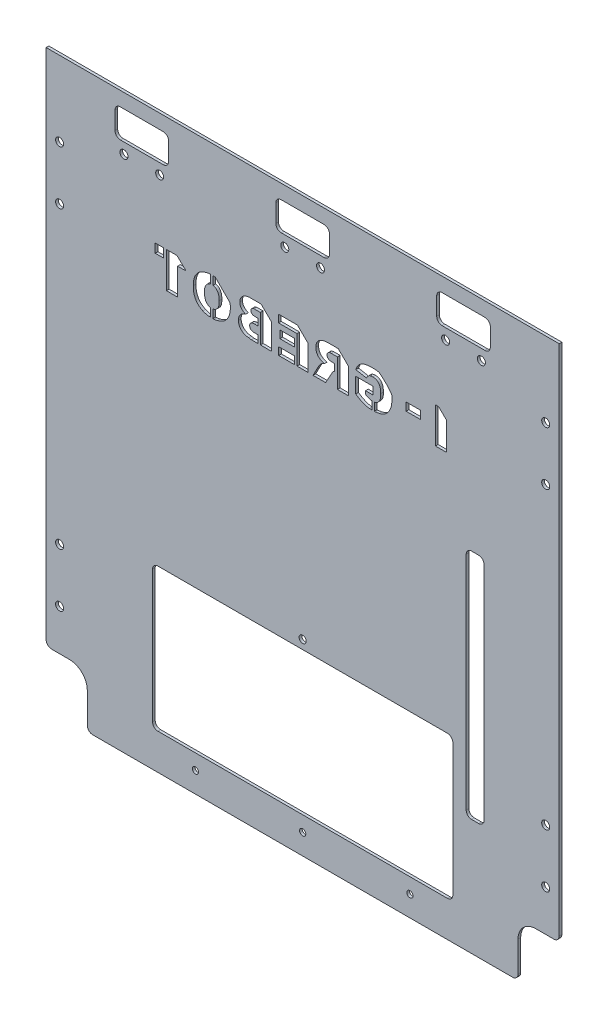
from build123d import *

# Parameters (mm, degrees)
ESQUISSE1_W                  = 287
ESQUISSE1_H                  = 320
BOSS_EXTRU_1_DEPTH           = 1.5
ESQUISSE2_W                  = 23
ESQUISSE2_H                  = 30
ENL_V_MAT_EXTRU_1_DEPTH      = 1
ENL_V_MAT_EXTRU_1_DEPTH_BACK = 2.5
CONG_1_R                     = 10
CONG_2_R                     = 3
ESQUISSE3_W                  = 10
ESQUISSE3_H                  = 130
ENL_V_MAT_EXTRU_2_DEPTH      = 1
ENL_V_MAT_EXTRU_2_DEPTH_BACK = 2.5
ESQUISSE4_W                  = 168
ESQUISSE4_H                  = 80
ENL_V_MAT_EXTRU_3_DEPTH      = 1
ENL_V_MAT_EXTRU_3_DEPTH_BACK = 2.5
CONG_3_R                     = 3
ESQUISSE5_R                  = 2
ESQUISSE5_R_2                = 1.75
ENL_V_MAT_EXTRU_4_DEPTH      = 1
ENL_V_MAT_EXTRU_4_DEPTH_BACK = 2.5
ESQUISSE6_R                  = 2.25
ENL_V_MAT_EXTRU_5_DEPTH      = 1
ENL_V_MAT_EXTRU_5_DEPTH_BACK = 2.5
ESQUISSE7_W                  = 30
ESQUISSE7_H                  = 16
ENL_V_MAT_EXTRU_6_DEPTH      = 1
ENL_V_MAT_EXTRU_6_DEPTH_BACK = 2.5
CONG_4_R                     = 3
ESQUISSE8_W                  = 8
ESQUISSE8_H                  = 4.5
ESQUISSE8_W_2                = 8.1015625
ESQUISSE8_H_2                = 4.25
ESQUISSE8_W_3                = 8.83203125
ESQUISSE8_W_4                = 4.75
ESQUISSE8_H_3                = 5
ENL_V_MAT_EXTRU_9_DEPTH      = 2.5
ENL_V_MAT_EXTRU_9_DEPTH_BACK = 1


with BuildPart() as part:
    # Esquisse1 → Boss.-Extru.1 (new body)
    with BuildSketch(Plane.XY):
        with Locations((143.5, 160)):
            Rectangle(ESQUISSE1_W, ESQUISSE1_H)
    extrude(amount=BOSS_EXTRU_1_DEPTH)

    # Esquisse2 → Enlèv. mat.-Extru.1 (cut, two sides)
    with BuildSketch(Plane.XY.offset(1.5)) as enl_v_mat_extru_1_sk:
        with Locations((275.5, 15)):
            Rectangle(ESQUISSE2_W, ESQUISSE2_H)
        with Locations((11.5, 15)):
            Rectangle(ESQUISSE2_W, ESQUISSE2_H)
    extrude(amount=ENL_V_MAT_EXTRU_1_DEPTH, mode=Mode.SUBTRACT)
    extrude(enl_v_mat_extru_1_sk.sketch, amount=-ENL_V_MAT_EXTRU_1_DEPTH_BACK, mode=Mode.SUBTRACT)

    # Congé1
    cong_1_edges = [part.edges().sort_by_distance(p)[0] for p in [
        (264, 30, 0.75),
        (23, 30, 0.75),
    ]]
    fillet(cong_1_edges, radius=CONG_1_R)

    # Congé2
    cong_2_edges = [part.edges().sort_by_distance(p)[0] for p in [
        (287, 30, 0.75),
        (264, 0, 0.75),
        (23, 0, 0.75),
        (0, 30, 0.75),
    ]]
    fillet(cong_2_edges, radius=CONG_2_R)

    # Esquisse3 → Enlèv. mat.-Extru.2 (cut, two sides)
    with BuildSketch(Plane.XY.offset(1.5)) as enl_v_mat_extru_2_sk:
        with Locations((240, 130)):
            Rectangle(ESQUISSE3_W, ESQUISSE3_H)
    extrude(amount=ENL_V_MAT_EXTRU_2_DEPTH, mode=Mode.SUBTRACT)
    extrude(enl_v_mat_extru_2_sk.sketch, amount=-ENL_V_MAT_EXTRU_2_DEPTH_BACK, mode=Mode.SUBTRACT)

    # Esquisse4 → Enlèv. mat.-Extru.3 (cut, two sides)
    with BuildSketch(Plane.XY.offset(1.5)) as enl_v_mat_extru_3_sk:
        with Locations((143.5, 60)):
            Rectangle(ESQUISSE4_W, ESQUISSE4_H)
    extrude(amount=ENL_V_MAT_EXTRU_3_DEPTH, mode=Mode.SUBTRACT)
    extrude(enl_v_mat_extru_3_sk.sketch, amount=-ENL_V_MAT_EXTRU_3_DEPTH_BACK, mode=Mode.SUBTRACT)

    # Congé3
    cong_3_edges = [part.edges().sort_by_distance(p)[0] for p in [
        (59.5, 20, 0.75),
        (59.5, 100, 0.75),
        (227.5, 100, 0.75),
        (227.5, 20, 0.75),
        (235, 65, 0.75),
        (235, 195, 0.75),
        (245, 195, 0.75),
        (245, 65, 0.75),
    ]]
    fillet(cong_3_edges, radius=CONG_3_R)

    # Esquisse5 → Enlèv. mat.-Extru.4 (cut, two sides)
    with BuildSketch(Plane.XY.offset(1.5)) as enl_v_mat_extru_4_sk:
        with Locations((143.5, 105)):
            Circle(ESQUISSE5_R)
        with Locations((83.5, 11.5)):
            Circle(ESQUISSE5_R_2)
        with Locations((143.5, 11.5)):
            Circle(ESQUISSE5_R_2)
        with Locations((203.5, 11.5)):
            Circle(ESQUISSE5_R_2)
    extrude(amount=ENL_V_MAT_EXTRU_4_DEPTH, mode=Mode.SUBTRACT)
    extrude(enl_v_mat_extru_4_sk.sketch, amount=-ENL_V_MAT_EXTRU_4_DEPTH_BACK, mode=Mode.SUBTRACT)

    # Esquisse6 → Enlèv. mat.-Extru.5 (cut, two sides)
    with BuildSketch(Plane.XY.offset(1.5)) as enl_v_mat_extru_5_sk:
        with Locations((279.5, 83)):
            Circle(ESQUISSE6_R)
        with Locations((279.5, 53)):
            Circle(ESQUISSE6_R)
        with Locations((279.5, 278)):
            Circle(ESQUISSE6_R)
        with Locations((279.5, 248)):
            Circle(ESQUISSE6_R)
        with Locations((7.5, 248)):
            Circle(ESQUISSE6_R)
        with Locations((7.5, 278)):
            Circle(ESQUISSE6_R)
        with Locations((7.5, 53)):
            Circle(ESQUISSE6_R)
        with Locations((7.5, 83)):
            Circle(ESQUISSE6_R)
        with Locations((133.5, 290)):
            Circle(ESQUISSE6_R)
        with Locations((153.5, 290)):
            Circle(ESQUISSE6_R)
        with Locations((43.5, 290)):
            Circle(ESQUISSE6_R)
        with Locations((63.5, 290)):
            Circle(ESQUISSE6_R)
        with Locations((223.5, 290)):
            Circle(ESQUISSE6_R)
        with Locations((243.5, 290)):
            Circle(ESQUISSE6_R)
    extrude(amount=ENL_V_MAT_EXTRU_5_DEPTH, mode=Mode.SUBTRACT)
    extrude(enl_v_mat_extru_5_sk.sketch, amount=-ENL_V_MAT_EXTRU_5_DEPTH_BACK, mode=Mode.SUBTRACT)

    # Esquisse7 → Enlèv. mat.-Extru.6 (cut, two sides)
    with BuildSketch(Plane.XY.offset(1.5)) as enl_v_mat_extru_6_sk:
        with Locations((143.5, 304)):
            Rectangle(ESQUISSE7_W, ESQUISSE7_H)
        with Locations((53.5, 304)):
            Rectangle(ESQUISSE7_W, ESQUISSE7_H)
        with Locations((233.5, 304)):
            Rectangle(ESQUISSE7_W, ESQUISSE7_H)
    extrude(amount=ENL_V_MAT_EXTRU_6_DEPTH, mode=Mode.SUBTRACT)
    extrude(enl_v_mat_extru_6_sk.sketch, amount=-ENL_V_MAT_EXTRU_6_DEPTH_BACK, mode=Mode.SUBTRACT)

    # Congé4
    cong_4_edges = [part.edges().sort_by_distance(p)[0] for p in [
        (158.5, 296, 0.75),
        (128.5, 296, 0.75),
        (128.5, 312, 0.75),
        (158.5, 312, 0.75),
        (68.5, 296, 0.75),
        (38.5, 296, 0.75),
        (38.5, 312, 0.75),
        (68.5, 312, 0.75),
        (218.5, 312, 0.75),
        (248.5, 312, 0.75),
        (248.5, 296, 0.75),
        (218.5, 296, 0.75),
    ]]
    fillet(cong_4_edges, radius=CONG_4_R)

    # Esquisse8 → Enlèv. mat.-Extru.9 (cut, two sides)
    with BuildSketch(Plane.XY) as enl_v_mat_extru_9_sk:
        with Locations((205.40307235, 246.717470335)):
            Rectangle(ESQUISSE8_W, ESQUISSE8_H)
        Polygon((217.808470064, 235.82100052), (224.058470064, 235.82100052), (224.058470064, 251.35615677), (219.554563814, 255.82100052), (217.808470064, 255.82100052), align=None)
        with BuildLine():
            add(Edge.make_bspline(
                [(173.195970064, 238.68428177), (173.506575511, 238.476890691), (174.124030723, 238.064616198), (175.081740291, 237.500188658), (176.060170837, 236.990331228), (177.048885734, 236.534146379), (178.03415498, 236.149028744), (179.004739272, 235.859814208), (179.950320427, 235.655338937), (180.576615749, 235.598734129), (180.883470064, 235.57100052)],
                knots=[0, 0, 0, 0, 0.001120277, 0.002227008, 0.00333298, 0.004428918, 0.005492394, 0.006503351, 0.007464805, 0.008388375, 0.008388375, 0.008388375, 0.008388375], degree=3))
            add(Edge.make_bspline(
                [(180.883470064, 235.57100052), (180.956386731, 235.57100052), (181.123053398, 235.57100052), (181.373053398, 235.57100052), (181.597011731, 235.57100052), (181.727220064, 235.57100052), (181.774095064, 235.57100052)],
                knots=[0, 0, 0, 0, 0.00021875, 0.0005, 0.00075, 0.000890625, 0.000890625, 0.000890625, 0.000890625], degree=3))
            Line((181.774095064, 235.57100052), (182.340501314, 235.57100052))
            Line((182.340501314, 235.57100052), (182.340501314, 239.92646927))
            add(Edge.make_bspline(
                [(182.340501314, 239.92646927), (182.010963338, 239.979571057), (181.357346222, 240.084894993), (180.562803563, 240.316303619), (179.951024259, 240.551407006), (179.513510291, 240.772898853), (179.090921227, 241.026275912), (178.82838844, 241.224782459), (178.695970064, 241.32490677)],
                knots=[0, 0, 0, 0, 0.001000641, 0.001984706, 0.002475791, 0.002964931, 0.003453977, 0.003951683, 0.003951683, 0.003951683, 0.003951683], degree=3))
            Line((178.695970064, 241.32490677), (178.695970064, 243.07100052))
            Line((178.695970064, 243.07100052), (182.879563814, 243.07100052))
            Line((182.879563814, 243.07100052), (182.879563814, 247.32100052))
            Line((182.879563814, 247.32100052), (173.195970064, 247.32100052))
            Line((173.195970064, 247.32100052), (173.195970064, 238.68428177))
        make_face()
        with BuildLine():
            Line((173.293626314, 250.55146927), (178.856126314, 249.52412552))
            Line((178.856126314, 249.52412552), (179.285813814, 249.52412552))
            add(Edge.make_bspline(
                [(179.285813814, 249.52412552), (179.336154704, 249.644702546), (179.432958032, 249.876566886), (179.600852687, 250.199180903), (179.784282989, 250.481685008), (180.041005404, 250.799724919), (180.391033417, 251.128577135), (180.85376061, 251.423652978), (181.332932183, 251.629013222), (181.817262437, 251.746217036), (182.286681346, 251.808766376), (182.594238869, 251.817014956), (182.742845064, 251.82100052)],
                knots=[0, 0, 0, 0, 0.000391873, 0.000753555, 0.001089424, 0.001400554, 0.001978164, 0.002521034, 0.00303908, 0.003534574, 0.004011344, 0.004457085, 0.004457085, 0.004457085, 0.004457085], degree=3))
            add(Edge.make_bspline(
                [(182.742845064, 251.82100052), (182.97784203, 251.81449031), (183.42631942, 251.802065972), (184.060845308, 251.682019425), (184.626568121, 251.497206124), (185.107906003, 251.214265838), (185.522588467, 250.883128113), (185.886939282, 250.515696668), (186.199956279, 250.112711627), (186.461110572, 249.676981154), (186.676421177, 249.218099311), (186.84611099, 248.740983979), (186.982772985, 248.249473581), (187.066637417, 247.748715818), (187.123600302, 247.258021362), (187.160627911, 246.791357127), (187.192167949, 246.355274416), (187.19473514, 246.073657365), (187.195970064, 245.93818802)],
                knots=[0, 0, 0, 0, 0.000704209, 0.00134394, 0.001930724, 0.00248016, 0.003008472, 0.003519474, 0.004028922, 0.00453538, 0.005040391, 0.005547, 0.006053021, 0.00656872, 0.007068262, 0.007534745, 0.007973098, 0.008379423, 0.008379423, 0.008379423, 0.008379423], degree=3))
            add(Edge.make_bspline(
                [(187.195970064, 245.93818802), (187.190649886, 245.669855046), (187.179374066, 245.101138317), (187.122077147, 244.376581303), (187.046877928, 243.767068206), (186.948561312, 243.308423519), (186.812950063, 242.861917369), (186.653611626, 242.423167763), (186.443609399, 242.004000166), (186.195680439, 241.602657885), (185.892441631, 241.231848565), (185.55663735, 240.874734006), (185.155219611, 240.562533918), (184.686418742, 240.313616316), (184.157748709, 240.114048435), (183.776874163, 240.036904222), (183.578782564, 239.99678177)],
                knots=[0, 0, 0, 0, 0.000805029, 0.001706213, 0.002179112, 0.00264646, 0.003111156, 0.003578406, 0.004044839, 0.004515214, 0.004990446, 0.005479414, 0.005983381, 0.00650775, 0.00706644, 0.007671921, 0.007671921, 0.007671921, 0.007671921], degree=3))
            Line((183.578782564, 239.99678177), (183.578782564, 235.57100052))
            Line((183.578782564, 235.57100052), (184.121751314, 235.57100052))
            add(Edge.make_bspline(
                [(184.121751314, 235.57100052), (184.15691054, 235.573555002), (184.265082659, 235.581414212), (184.47119009, 235.599090965), (184.754529823, 235.636347134), (185.088933476, 235.674429016), (185.448530211, 235.736678992), (185.817239638, 235.793368752), (186.167058912, 235.867220753), (186.391388784, 235.920824217), (186.496751314, 235.94600052)],
                knots=[0, 0, 0, 0, 0.000105758, 0.000325378, 0.000620448, 0.000962998, 0.001334831, 0.001715004, 0.002081963, 0.002406957, 0.002406957, 0.002406957, 0.002406957], degree=3))
            add(Edge.make_bspline(
                [(186.496751314, 235.94600052), (186.662612098, 235.983109076), (186.990146218, 236.056389319), (187.465479422, 236.198428745), (187.920594462, 236.358545175), (188.354682575, 236.538753763), (188.769979652, 236.736175342), (189.160337699, 236.9600823), (189.53062444, 237.20269951), (189.988217318, 237.555451019), (190.516010405, 238.029204294), (191.084007536, 238.641381576), (191.589874559, 239.287733847), (192.017604439, 239.976709849), (192.378190047, 240.693666504), (192.689298293, 241.424741514), (192.940306741, 242.173092589), (193.128761214, 242.931742428), (193.266097281, 243.685525878), (193.367934857, 244.419218067), (193.435106364, 245.12834141), (193.442394003, 245.592994275), (193.445970064, 245.82100052)],
                knots=[0, 0, 0, 0, 0.000509747, 0.001006624, 0.00148722, 0.001956572, 0.002416067, 0.002865693, 0.003305559, 0.003743076, 0.004597867, 0.005429825, 0.006245558, 0.007056291, 0.007858148, 0.008651126, 0.009437991, 0.01022339, 0.010994139, 0.011735504, 0.012445292, 0.013129165, 0.013129165, 0.013129165, 0.013129165], degree=3))
            add(Edge.make_bspline(
                [(193.445970064, 245.82100052), (193.445880337, 245.968136048), (193.445697705, 246.267615441), (193.447104661, 246.719442178), (193.441842592, 247.166092738), (193.438649849, 247.596096251), (193.411360562, 248.000822611), (193.34421549, 248.371673314), (193.256934469, 248.700923393), (193.145237132, 248.880092088), (193.094407564, 248.96162552)],
                knots=[0, 0, 0, 0, 0.000441406, 0.000898437, 0.001355485, 0.001781338, 0.002188789, 0.002569623, 0.002913106, 0.003199943, 0.003199943, 0.003199943, 0.003199943], degree=3))
            add(Edge.make_bspline(
                [(193.094407564, 248.96162552), (192.854550004, 249.2695013), (192.372846999, 249.887804463), (191.604518746, 250.785097454), (190.800079467, 251.665199844), (189.955437648, 252.522011055), (189.083462986, 253.361905028), (188.179154336, 254.171334401), (187.258051787, 254.965118443), (186.623440187, 255.470183531), (186.305345064, 255.72334427)],
                knots=[0, 0, 0, 0, 0.001170709, 0.002351121, 0.003542757, 0.004747099, 0.005959932, 0.007174172, 0.008387628, 0.009607135, 0.009607135, 0.009607135, 0.009607135], degree=3))
            add(Edge.make_bspline(
                [(186.305345064, 255.72334427), (186.26935064, 255.741567875), (186.163787531, 255.795013385), (185.94337712, 255.832502455), (185.652994511, 255.888454989), (185.311881943, 255.935119257), (184.946654699, 255.987769129), (184.576550236, 256.027566019), (184.236876512, 256.061253522), (184.024152594, 256.068017655), (183.930345064, 256.07100052)],
                knots=[0, 0, 0, 0, 0.000120589, 0.000353658, 0.000663214, 0.001010695, 0.001385247, 0.001770464, 0.002127303, 0.002408797, 0.002408797, 0.002408797, 0.002408797], degree=3))
            add(Edge.make_bspline(
                [(183.930345064, 256.07100052), (183.813157564, 256.07100052), (183.543626314, 256.07100052), (183.195970064, 256.07100052), (182.903001314, 256.07100052), (182.716803398, 256.07100052), (182.578782564, 256.07100052), (182.503261731, 256.07100052), (182.473313814, 256.07100052)],
                knots=[0, 0, 0, 0, 0.000351562, 0.000808594, 0.001042969, 0.001230469, 0.001367188, 0.001457031, 0.001457031, 0.001457031, 0.001457031], degree=3))
            add(Edge.make_bspline(
                [(182.473313814, 256.07100052), (182.040842032, 256.065017718), (181.157820725, 256.052802027), (180.047785286, 255.967518086), (179.146568372, 255.860265255), (178.478616259, 255.711359143), (177.826528903, 255.517290349), (177.18845284, 255.270513321), (176.570787704, 254.964101809), (175.980249258, 254.58389935), (175.41635368, 254.137876568), (174.975592845, 253.708663087), (174.639663437, 253.330839652), (174.403244642, 253.013786861), (174.183427132, 252.670070993), (173.96851457, 252.302967714), (173.780471423, 251.9019041), (173.600619166, 251.477621048), (173.434539314, 251.025737953), (173.34137706, 250.71218321), (173.293626314, 250.55146927)],
                knots=[0, 0, 0, 0, 0.001297251, 0.002648729, 0.003338202, 0.004017811, 0.004698765, 0.005377745, 0.006067782, 0.006763446, 0.007480878, 0.008221213, 0.008605954, 0.008996579, 0.009406139, 0.009829603, 0.010271631, 0.010733775, 0.011212016, 0.011714891, 0.011714891, 0.011714891, 0.011714891], degree=3))
        make_face()
        with BuildLine():
            Line((149.314720064, 235.82100052), (156.314720064, 235.82100052))
            add(Edge.make_bspline(
                [(156.314720064, 235.82100052), (156.477302735, 236.117973252), (156.816192267, 236.736987262), (157.34053737, 237.686292633), (157.879675156, 238.672062079), (158.422756379, 239.65232494), (158.942222648, 240.606684397), (159.375594731, 241.360987201), (159.700793347, 241.927082187), (159.930016711, 242.30702732), (160.137886182, 242.653996198), (160.276484767, 242.870774061), (160.342063814, 242.97334427)],
                knots=[0, 0, 0, 0, 0.001015693, 0.002117124, 0.003253466, 0.004386387, 0.00547909, 0.006513037, 0.006996102, 0.007437578, 0.007844222, 0.00820943, 0.00820943, 0.00820943, 0.00820943], degree=3))
            add(Edge.make_bspline(
                [(160.342063814, 242.97334427), (160.394785732, 243.04431627), (160.504390364, 243.191861356), (160.739415701, 243.354598616), (160.993390005, 243.50299423), (161.171043786, 243.595150771), (161.260032564, 243.64131302)],
                knots=[0, 0, 0, 0, 0.000263578, 0.000547957, 0.000847416, 0.001147969, 0.001147969, 0.001147969, 0.001147969], degree=3))
            Line((161.260032564, 243.64131302), (161.260032564, 247.53975052))
            add(Edge.make_bspline(
                [(161.260032564, 247.53975052), (161.187138913, 247.544297181), (161.02974771, 247.554114283), (160.774349589, 247.555507158), (160.483970818, 247.556643115), (160.050308234, 247.546859442), (159.488083785, 247.564960587), (158.92868774, 247.65090102), (158.497401409, 247.765716817), (158.196601914, 247.896359981), (157.915766782, 248.060008265), (157.650390283, 248.250082786), (157.423298699, 248.500241723), (157.266253078, 248.821622532), (157.173667952, 249.20256887), (157.163730349, 249.476684029), (157.158470064, 249.62178177)],
                knots=[0, 0, 0, 0, 0.000219064, 0.000473, 0.000765969, 0.001090211, 0.001774351, 0.002450595, 0.002783269, 0.00311051, 0.003430774, 0.003757338, 0.0040866, 0.004432496, 0.004819038, 0.005253756, 0.005253756, 0.005253756, 0.005253756], degree=3))
            add(Edge.make_bspline(
                [(157.158470064, 249.62178177), (157.162042215, 249.70782997), (157.168953839, 249.874321537), (157.205680312, 250.114318576), (157.277223561, 250.332662668), (157.408605635, 250.590425684), (157.614586318, 250.875554092), (157.932638637, 251.140890916), (158.295188407, 251.338505367), (158.690591618, 251.468923397), (159.096293462, 251.554095299), (159.36901297, 251.565452977), (159.502220064, 251.57100052)],
                knots=[0, 0, 0, 0, 0.000258286, 0.000499747, 0.000725804, 0.00094417, 0.001366063, 0.001770695, 0.002176287, 0.002597529, 0.003015808, 0.003415182, 0.003415182, 0.003415182, 0.003415182], degree=3))
            Line((159.502220064, 251.57100052), (162.908470064, 251.57100052))
            Line((162.908470064, 251.57100052), (162.908470064, 235.82100052))
            Line((162.908470064, 235.82100052), (169.158470064, 235.82100052))
            Line((169.158470064, 235.82100052), (169.158470064, 250.11787552))
            Line((169.158470064, 250.11787552), (163.385032564, 255.82100052))
            Line((163.385032564, 255.82100052), (158.049095064, 255.82100052))
            add(Edge.make_bspline(
                [(158.049095064, 255.82100052), (157.862824847, 255.819000934), (157.483374412, 255.814927584), (156.904960478, 255.772434774), (156.30667488, 255.710975663), (155.694807093, 255.622445826), (155.081345612, 255.50372869), (154.487088992, 255.326365168), (153.91579593, 255.102122467), (153.369188284, 254.830920301), (152.853890435, 254.503964391), (152.384031104, 254.109465247), (151.966659796, 253.64819596), (151.655931519, 253.219971203), (151.43770724, 252.845028256), (151.297392444, 252.536930703), (151.175858754, 252.209596972), (151.079218191, 251.858957924), (151.000695563, 251.488690522), (150.946431734, 251.095793947), (150.915935831, 250.682167327), (150.910994567, 250.399175472), (150.908470064, 250.25459427)],
                knots=[0, 0, 0, 0, 0.000558717, 0.00113816, 0.001739075, 0.002362768, 0.002992486, 0.00361171, 0.004220308, 0.004831733, 0.005439616, 0.006046796, 0.006666131, 0.00730141, 0.007630394, 0.007965968, 0.008315725, 0.008676837, 0.009056065, 0.0094505, 0.00986574, 0.010299492, 0.010299492, 0.010299492, 0.010299492], degree=3))
            add(Edge.make_bspline(
                [(150.908470064, 250.25459427), (150.911652071, 250.098238717), (150.917948486, 249.788849224), (150.962793329, 249.32972613), (151.031395186, 248.880359034), (151.13307542, 248.441200123), (151.267865396, 248.015027723), (151.447075432, 247.603476029), (151.664683733, 247.206820115), (151.923750947, 246.82517273), (152.226747825, 246.464750879), (152.571371773, 246.12412024), (152.960824174, 245.805899047), (153.397929573, 245.512785228), (153.882487243, 245.239827628), (154.427620582, 245.010476442), (155.021225804, 244.793921577), (155.44375098, 244.688202352), (155.662376314, 244.63350052)],
                knots=[0, 0, 0, 0, 0.00046901, 0.000928057, 0.001382745, 0.001831879, 0.002279072, 0.002721721, 0.003176258, 0.003634556, 0.004103193, 0.004586574, 0.005086238, 0.00560953, 0.006163846, 0.006751656, 0.007381762, 0.008057374, 0.008057374, 0.008057374, 0.008057374], degree=3))
            add(Edge.make_bspline(
                [(155.662376314, 244.63350052), (155.525405814, 244.564548282), (155.253077926, 244.427455862), (154.827102156, 244.267557353), (154.400971428, 244.101641128), (154.161281098, 243.914627165), (154.041282564, 243.82100052)],
                knots=[0, 0, 0, 0, 0.000459495, 0.000913579, 0.001366519, 0.001820619, 0.001820619, 0.001820619, 0.001820619], degree=3))
            add(Edge.make_bspline(
                [(154.041282564, 243.82100052), (153.897549347, 243.685919231), (153.601436539, 243.407630743), (153.209443134, 242.925208826), (152.833308977, 242.412229679), (152.491675752, 241.875965953), (152.163351556, 241.347032988), (151.887306864, 240.817277271), (151.629313263, 240.321944684), (151.471703156, 240.000979829), (151.396751314, 239.84834427)],
                knots=[0, 0, 0, 0, 0.000591123, 0.001217805, 0.001860831, 0.002498998, 0.003124706, 0.003727649, 0.004290204, 0.00480031, 0.00480031, 0.00480031, 0.00480031], degree=3))
            add(Edge.make_bspline(
                [(151.396751314, 239.84834427), (151.321450516, 239.699794062), (151.166631257, 239.394373221), (150.923242077, 238.924933358), (150.665453593, 238.428827012), (150.30473075, 237.736763933), (149.841719761, 236.870160386), (149.489068222, 236.168095767), (149.314720064, 235.82100052)],
                knots=[0, 0, 0, 0, 0.000499634, 0.001027252, 0.001586337, 0.002176892, 0.003368548, 0.00453377, 0.00453377, 0.00453377, 0.00453377], degree=3))
        make_face()
        with Locations((134.890501314, 246.44600052)):
            Rectangle(ESQUISSE8_W_2, ESQUISSE8_H_2)
        Polygon((129.972532564, 251.57100052), (140.370970064, 251.57100052), (140.370970064, 235.82100052), (146.620970064, 235.82100052), (146.620970064, 249.86787552), (140.535032564, 255.82100052), (129.972532564, 255.82100052), align=None)
        with Locations((134.525266939, 237.94600052)):
            Rectangle(ESQUISSE8_W_3, ESQUISSE8_H_2)
        with BuildLine():
            add(Edge.make_bspline(
                [(107.583470064, 241.63350052), (107.588469173, 241.458859458), (107.598465444, 241.109645294), (107.663968414, 240.589632371), (107.78475253, 240.079798047), (107.942040163, 239.580224145), (108.148714214, 239.101217147), (108.400812653, 238.645890737), (108.702032721, 238.221283931), (109.04772262, 237.825057759), (109.435860546, 237.458984768), (109.871912178, 237.130995571), (110.352779155, 236.837231759), (110.873696953, 236.575619796), (111.438642433, 236.357384876), (112.047540432, 236.204923463), (112.695860043, 236.099441851), (113.142935645, 236.080650745), (113.372532564, 236.07100052)],
                knots=[0, 0, 0, 0, 0.000523962, 0.00104772, 0.001568879, 0.002093903, 0.002617078, 0.003131176, 0.003652482, 0.004175759, 0.004706348, 0.005250103, 0.005809515, 0.006394736, 0.006996869, 0.007622174, 0.008274658, 0.0089635, 0.0089635, 0.0089635, 0.0089635], degree=3))
            add(Edge.make_bspline(
                [(113.372532564, 236.07100052), (113.423407934, 236.069421309), (113.537478434, 236.065880473), (113.718257096, 236.035391495), (113.920402168, 235.997627123), (114.12688601, 235.947841795), (114.32712954, 235.894034514), (114.50660401, 235.860283638), (114.645039712, 235.828659672), (114.722718181, 235.823067978), (114.751438814, 235.82100052)],
                knots=[0, 0, 0, 0, 0.000152544, 0.000342027, 0.000548874, 0.000769638, 0.000979014, 0.00117054, 0.001317635, 0.001403927, 0.001403927, 0.001403927, 0.001403927], degree=3))
            Line((114.751438814, 235.82100052), (118.474095064, 235.82100052))
            Line((118.474095064, 235.82100052), (118.474095064, 240.07100052))
            Line((118.474095064, 240.07100052), (115.829563814, 240.07100052))
            add(Edge.make_bspline(
                [(115.829563814, 240.07100052), (115.770780049, 240.07773123), (115.624061023, 240.094530482), (115.385358327, 240.15624781), (115.123915879, 240.246448096), (114.961266225, 240.339459465), (114.884251314, 240.38350052)],
                knots=[0, 0, 0, 0, 0.000177337, 0.000442617, 0.000737972, 0.001003597, 0.001003597, 0.001003597, 0.001003597], degree=3))
            add(Edge.make_bspline(
                [(114.884251314, 240.38350052), (114.799374183, 240.433269582), (114.632276656, 240.531249886), (114.411922602, 240.715764271), (114.229146417, 240.930206977), (114.085552093, 241.170793791), (113.972935593, 241.428546764), (113.890635939, 241.697083668), (113.842424064, 241.974211665), (113.836469844, 242.160660155), (113.833470064, 242.25459427)],
                knots=[0, 0, 0, 0, 0.000294812, 0.000580396, 0.000857492, 0.00113618, 0.001417783, 0.001699521, 0.001976947, 0.002258631, 0.002258631, 0.002258631, 0.002258631], degree=3))
            add(Edge.make_bspline(
                [(113.833470064, 242.25459427), (113.835816822, 242.357702886), (113.840305011, 242.554898746), (113.89172237, 242.833585298), (113.973752487, 243.081565031), (114.124745989, 243.365694082), (114.378314757, 243.667957695), (114.761306232, 243.936553537), (115.190507686, 244.12754384), (115.64239111, 244.240803322), (116.081360975, 244.30883238), (116.367113229, 244.317109592), (116.501438814, 244.32100052)],
                knots=[0, 0, 0, 0, 0.000308989, 0.000590943, 0.000846646, 0.001089526, 0.001552659, 0.002014473, 0.002481299, 0.0029541, 0.003408201, 0.003811018, 0.003811018, 0.003811018, 0.003811018], degree=3))
            Line((116.501438814, 244.32100052), (118.415501314, 244.32100052))
            Line((118.415501314, 244.32100052), (118.415501314, 248.07100052))
            Line((118.415501314, 248.07100052), (116.446751314, 248.07100052))
            add(Edge.make_bspline(
                [(116.446751314, 248.07100052), (116.418058414, 248.073203281), (116.349862029, 248.078438736), (116.231084231, 248.099653664), (116.079921605, 248.135101606), (115.84271364, 248.201884442), (115.54704115, 248.295399855), (115.33203657, 248.414139984), (115.231907564, 248.46943802)],
                knots=[0, 0, 0, 0, 8.6292e-05, 0.000205096, 0.000361443, 0.000551931, 0.000944776, 0.001287192, 0.001287192, 0.001287192, 0.001287192], degree=3))
            add(Edge.make_bspline(
                [(115.231907564, 248.46943802), (115.171357128, 248.511444859), (115.053825849, 248.592982133), (114.913207276, 248.750861877), (114.796392248, 248.918773092), (114.691111863, 249.166253469), (114.6068041, 249.484820458), (114.591118772, 249.744938988), (114.583470064, 249.87178177)],
                knots=[0, 0, 0, 0, 0.000220314, 0.00042764, 0.000630238, 0.000831325, 0.001231158, 0.001611691, 0.001611691, 0.001611691, 0.001611691], degree=3))
            add(Edge.make_bspline(
                [(114.583470064, 249.87178177), (114.589786159, 249.992432799), (114.601979968, 250.225360843), (114.709403029, 250.555778208), (114.879629553, 250.852704832), (115.120411471, 251.102284648), (115.401037271, 251.308719507), (115.711373821, 251.4654641), (116.051583695, 251.551715909), (116.284842197, 251.564487953), (116.403782564, 251.57100052)],
                knots=[0, 0, 0, 0, 0.000361091, 0.000697119, 0.00103144, 0.001379644, 0.001728877, 0.002073026, 0.002415999, 0.002772838, 0.002772838, 0.002772838, 0.002772838], degree=3))
            Line((116.403782564, 251.57100052), (119.833470064, 251.57100052))
            Line((119.833470064, 251.57100052), (119.833470064, 235.82100052))
            Line((119.833470064, 235.82100052), (126.083470064, 235.82100052))
            Line((126.083470064, 235.82100052), (126.083470064, 250.05537552))
            Line((126.083470064, 250.05537552), (120.239720064, 255.82100052))
            Line((120.239720064, 255.82100052), (113.630345064, 255.82100052))
            add(Edge.make_bspline(
                [(113.630345064, 255.82100052), (113.60038805, 255.81989158), (113.524720305, 255.817090534), (113.390288192, 255.805519765), (113.21264086, 255.778474665), (112.92721016, 255.747397534), (112.576288079, 255.690232832), (112.306912136, 255.613521282), (112.185032564, 255.57881302)],
                knots=[0, 0, 0, 0, 8.9929e-05, 0.000227149, 0.000404486, 0.000628815, 0.001088625, 0.001468577, 0.001468577, 0.001468577, 0.001468577], degree=3))
            add(Edge.make_bspline(
                [(112.185032564, 255.57881302), (112.013728265, 255.523604402), (111.680598835, 255.416242151), (111.207112273, 255.22529941), (110.774877456, 255.011575222), (110.387204514, 254.770262117), (110.034007316, 254.516655863), (109.716177602, 254.247846061), (109.436752509, 253.960878084), (109.194466317, 253.658498595), (108.982161437, 253.345263838), (108.801784257, 253.019778962), (108.652088743, 252.68260205), (108.498181047, 252.217230911), (108.361274215, 251.615004682), (108.342756888, 251.122626104), (108.333470064, 250.87568802)],
                knots=[0, 0, 0, 0, 0.000539812, 0.001049754, 0.001530159, 0.001984394, 0.002418058, 0.002833702, 0.003231488, 0.003617654, 0.003994683, 0.004365365, 0.004732636, 0.005099511, 0.005835049, 0.006575075, 0.006575075, 0.006575075, 0.006575075], degree=3))
            add(Edge.make_bspline(
                [(108.333470064, 250.87568802), (108.341725847, 250.664137304), (108.358138655, 250.243566507), (108.490567409, 249.624067456), (108.715189414, 249.028247656), (108.96458503, 248.549826576), (109.218637762, 248.183290062), (109.450416876, 247.92023059), (109.713581825, 247.663131612), (110.01660445, 247.421223109), (110.357052562, 247.191534389), (110.734310993, 246.973908773), (111.14381787, 246.761389337), (111.434203861, 246.635639378), (111.583470064, 246.57100052)],
                knots=[0, 0, 0, 0, 0.00063427, 0.001260952, 0.001890052, 0.0025401, 0.002873873, 0.003225544, 0.003590187, 0.003976353, 0.004386974, 0.004821113, 0.005282332, 0.005770176, 0.005770176, 0.005770176, 0.005770176], degree=3))
            add(Edge.make_bspline(
                [(111.583470064, 246.57100052), (111.409673106, 246.516840171), (111.072156193, 246.41165977), (110.588586343, 246.227485345), (110.142600444, 246.023574326), (109.740013093, 245.788984002), (109.368856132, 245.546992564), (109.043846601, 245.273229018), (108.752302018, 244.985284255), (108.501990451, 244.67444835), (108.28507342, 244.346640192), (108.099358496, 244.003154433), (107.936421682, 243.646710948), (107.808947453, 243.273196542), (107.705619169, 242.885935213), (107.637308786, 242.481764565), (107.592832684, 242.062876301), (107.586624144, 241.778148642), (107.583470064, 241.63350052)],
                knots=[0, 0, 0, 0, 0.000546009, 0.00106036, 0.001551446, 0.002015123, 0.002457151, 0.002878773, 0.003287569, 0.003684721, 0.004073663, 0.004465224, 0.004855107, 0.005247952, 0.005647785, 0.006056226, 0.006476398, 0.006910273, 0.006910273, 0.006910273, 0.006910273], degree=3))
        make_face()
        with BuildLine():
            add(Edge.make_bspline(
                [(82.295970064, 245.78975052), (82.304048119, 245.351933129), (82.32031529, 244.470278996), (82.43591758, 243.37015339), (82.579498129, 242.490009998), (82.745709596, 241.837699759), (82.958010888, 241.194619005), (83.214241788, 240.560667932), (83.527369404, 239.939419521), (83.906799016, 239.337314051), (84.339575955, 238.744661849), (84.842643184, 238.172073243), (85.419263787, 237.621077705), (86.083946147, 237.104495838), (86.83814066, 236.623704538), (87.382228448, 236.339063248), (87.663157564, 236.19209427)],
                knots=[0, 0, 0, 0, 0.001313203, 0.002644461, 0.003314266, 0.003986924, 0.004661383, 0.005344698, 0.00603649, 0.006745364, 0.007477429, 0.008235886, 0.009028855, 0.009866515, 0.010757217, 0.011708066, 0.011708066, 0.011708066, 0.011708066], degree=3))
            add(Edge.make_bspline(
                [(87.663157564, 236.19209427), (87.691675482, 236.180039216), (87.759657956, 236.151301763), (87.882718951, 236.110954347), (88.037744445, 236.050361595), (88.298477976, 235.955050299), (88.669943283, 235.829382674), (89.150076996, 235.682758615), (89.660002574, 235.548956694), (90.16785021, 235.429341874), (90.643337925, 235.340791698), (90.946707845, 235.327198488), (91.085032564, 235.32100052)],
                knots=[0, 0, 0, 0, 9.2851e-05, 0.000221342, 0.000388217, 0.000592129, 0.001054125, 0.00156447, 0.002097913, 0.002635175, 0.003130299, 0.003545263, 0.003545263, 0.003545263, 0.003545263], degree=3))
            Line((91.085032564, 235.32100052), (91.920970064, 235.32100052))
            Line((91.920970064, 235.32100052), (91.920970064, 239.99678177))
            add(Edge.make_bspline(
                [(91.920970064, 239.99678177), (91.794534201, 240.035440689), (91.538148438, 240.113832975), (91.154062611, 240.239538049), (90.780565831, 240.383893446), (90.548734155, 240.510001101), (90.436595064, 240.57100052)],
                knots=[0, 0, 0, 0, 0.000396614, 0.000804252, 0.001212637, 0.00159525, 0.00159525, 0.00159525, 0.00159525], degree=3))
            add(Edge.make_bspline(
                [(90.436595064, 240.57100052), (90.339646285, 240.633561958), (90.147246288, 240.757718452), (89.890103153, 240.990975893), (89.658204435, 241.255678676), (89.393587051, 241.666785959), (89.112289547, 242.230271851), (88.871555968, 242.962417014), (88.706873502, 243.722903164), (88.611578563, 244.484289773), (88.55522184, 245.209439168), (88.548940611, 245.677681991), (88.545970064, 245.89912552)],
                knots=[0, 0, 0, 0, 0.000345631, 0.000685924, 0.001037595, 0.001398368, 0.002149547, 0.002920356, 0.00370419, 0.004480395, 0.005220698, 0.005884945, 0.005884945, 0.005884945, 0.005884945], degree=3))
            add(Edge.make_bspline(
                [(88.545970064, 245.89912552), (88.551970351, 246.151868317), (88.56437093, 246.674202941), (88.630693384, 247.334267616), (88.721494948, 247.874089526), (88.813091275, 248.281764834), (88.945676988, 248.677662581), (89.095496863, 249.07039221), (89.279999769, 249.451859343), (89.518838035, 249.807380131), (89.793651197, 250.145825554), (90.110353641, 250.464656682), (90.478154445, 250.752945478), (90.90665244, 250.991654069), (91.391215792, 251.185060666), (91.739962479, 251.269409189), (91.920970064, 251.31318802)],
                knots=[0, 0, 0, 0, 0.000758306, 0.001567164, 0.001987154, 0.002400275, 0.002819046, 0.003238327, 0.003661088, 0.004086869, 0.004520022, 0.004967488, 0.005432398, 0.005916915, 0.006434106, 0.006992207, 0.006992207, 0.006992207, 0.006992207], degree=3))
            Line((91.920970064, 251.31318802), (91.920970064, 256.07100052))
            Line((91.920970064, 256.07100052), (91.167063814, 256.07100052))
            add(Edge.make_bspline(
                [(91.167063814, 256.07100052), (91.033856077, 256.063718873), (90.733652002, 256.047308566), (90.259680452, 255.943907814), (89.744546625, 255.821117778), (89.233547862, 255.68078082), (88.761273206, 255.545414325), (88.408226902, 255.428227891), (88.168204282, 255.352713569), (88.03664801, 255.310003078), (87.946086946, 255.280447511), (87.901375402, 255.261269176), (87.885813814, 255.25459427)],
                knots=[0, 0, 0, 0, 0.000399661, 0.000900698, 0.00145116, 0.001989387, 0.002490012, 0.002924853, 0.003105219, 0.003244809, 0.003339933, 0.003390714, 0.003390714, 0.003390714, 0.003390714], degree=3))
            add(Edge.make_bspline(
                [(87.885813814, 255.25459427), (87.595302249, 255.128719859), (87.031630026, 254.884488932), (86.253182855, 254.434486947), (85.560633572, 253.937125626), (84.963677903, 253.378821119), (84.446105864, 252.787313796), (83.989243829, 252.175228034), (83.59576762, 251.540544296), (83.271406695, 250.883651835), (82.995669373, 250.219728504), (82.779960089, 249.550814219), (82.603292739, 248.884016387), (82.487311125, 248.219162677), (82.404434482, 247.572036001), (82.338968008, 246.95098971), (82.303689307, 246.360486972), (82.298488935, 245.975987899), (82.295970064, 245.78975052)],
                knots=[0, 0, 0, 0, 0.000949162, 0.001841636, 0.002691728, 0.003501604, 0.004287624, 0.005047006, 0.005790672, 0.006524382, 0.007242537, 0.007945413, 0.008631357, 0.009310214, 0.009968194, 0.010588537, 0.011183327, 0.011742044, 0.011742044, 0.011742044, 0.011742044], degree=3))
        make_face()
        with BuildLine():
            add(Edge.make_bspline(
                [(93.366282564, 251.39521927), (93.551066449, 251.358261684), (93.907277139, 251.287017986), (94.406657643, 251.106829865), (94.845301646, 250.862954416), (95.223359656, 250.561540628), (95.545849258, 250.220190796), (95.825103769, 249.851387613), (96.071355693, 249.462276884), (96.261044294, 249.042372267), (96.423240627, 248.613330089), (96.545546311, 248.17315758), (96.647260829, 247.728057075), (96.72129409, 247.140333638), (96.779174529, 246.449792619), (96.790616507, 245.909659514), (96.795970064, 245.65693802)],
                knots=[0, 0, 0, 0, 0.000564788, 0.00108875, 0.001585397, 0.002063685, 0.002533378, 0.002990426, 0.003450037, 0.003911389, 0.004369953, 0.00482496, 0.005280855, 0.00573827, 0.006600516, 0.007358691, 0.007358691, 0.007358691, 0.007358691], degree=3))
            add(Edge.make_bspline(
                [(96.795970064, 245.65693802), (96.790837118, 245.383381545), (96.780164911, 244.814614384), (96.722668471, 244.096614318), (96.647941184, 243.506210714), (96.546087805, 243.071444334), (96.423382997, 242.646923056), (96.263801003, 242.238552786), (96.068527307, 241.845705661), (95.82519317, 241.481204165), (95.54399678, 241.13587034), (95.221614199, 240.814237505), (94.843740863, 240.52815441), (94.402891581, 240.299357766), (93.907552007, 240.112537319), (93.551193687, 240.036326748), (93.366282564, 239.99678177)],
                knots=[0, 0, 0, 0, 0.000820647, 0.001706255, 0.002159801, 0.002604256, 0.00304426, 0.003484576, 0.003917818, 0.004357683, 0.004796333, 0.005252093, 0.005720843, 0.006211882, 0.006737197, 0.007303765, 0.007303765, 0.007303765, 0.007303765], degree=3))
            Line((93.366282564, 239.99678177), (93.366282564, 235.32100052))
            Line((93.366282564, 235.32100052), (93.987376314, 235.32100052))
            add(Edge.make_bspline(
                [(93.987376314, 235.32100052), (94.018635126, 235.323500408), (94.109951377, 235.330803324), (94.278131004, 235.349215684), (94.504033298, 235.382827968), (94.768495053, 235.412234059), (95.055378624, 235.466713649), (95.351328817, 235.522047665), (95.636229401, 235.583473165), (95.81944906, 235.625511225), (95.905345064, 235.64521927)],
                knots=[0, 0, 0, 0, 9.4075e-05, 0.000274821, 0.000507399, 0.000779213, 0.001072702, 0.001382972, 0.001682534, 0.001946921, 0.001946921, 0.001946921, 0.001946921], degree=3))
            add(Edge.make_bspline(
                [(95.905345064, 235.64521927), (96.083037632, 235.692672327), (96.431840102, 235.785820531), (96.935512415, 235.95761555), (97.417656779, 236.135233349), (97.874867223, 236.331495077), (98.309922054, 236.539946124), (98.715289336, 236.773191117), (99.10042114, 237.014156257), (99.574392596, 237.355920619), (100.118399976, 237.812787936), (100.70261179, 238.405337302), (101.219125905, 239.031669209), (101.657636376, 239.698505229), (102.0215009, 240.396904744), (102.335321105, 241.11271483), (102.575006657, 241.854475684), (102.758974644, 242.610893393), (102.881872035, 243.376088094), (102.977763203, 244.135461971), (103.03348106, 244.889177721), (103.041817526, 245.388623955), (103.045970064, 245.63740677)],
                knots=[0, 0, 0, 0, 0.000551598, 0.001082762, 0.001595731, 0.002092747, 0.002574928, 0.003041998, 0.003494988, 0.003937275, 0.004794027, 0.005622687, 0.00643045, 0.007225676, 0.008011988, 0.008790597, 0.009567587, 0.010347322, 0.011123723, 0.011891189, 0.01264318, 0.01338953, 0.01338953, 0.01338953, 0.01338953], degree=3))
            add(Edge.make_bspline(
                [(103.045970064, 245.63740677), (103.045931264, 245.669958296), (103.045817965, 245.765008751), (103.047468337, 245.943458566), (103.037896873, 246.185689849), (103.024644056, 246.472573467), (102.992213953, 246.785165096), (102.950674474, 247.109956865), (102.896599616, 247.42639642), (102.828385201, 247.625042455), (102.795970064, 247.71943802)],
                knots=[0, 0, 0, 0, 9.7656e-05, 0.000285156, 0.000535278, 0.000824763, 0.001146596, 0.001477523, 0.00180771, 0.002106685, 0.002106685, 0.002106685, 0.002106685], degree=3))
            add(Edge.make_bspline(
                [(102.795970064, 247.71943802), (102.778541532, 247.768692607), (102.738832727, 247.880913235), (102.61729698, 248.04100607), (102.461379212, 248.215126737), (102.271080395, 248.396524194), (102.06741848, 248.589967329), (101.853818426, 248.783843214), (101.647395334, 248.966445992), (101.522020536, 249.091289791), (101.463938814, 249.14912552)],
                knots=[0, 0, 0, 0, 0.000155957, 0.000355329, 0.000596031, 0.000858448, 0.001143069, 0.00143894, 0.001723775, 0.001969621, 0.001969621, 0.001969621, 0.001969621], degree=3))
            add(Edge.make_bspline(
                [(101.463938814, 249.14912552), (101.207337651, 249.410755383), (100.678011882, 249.950454526), (99.866773725, 250.781147875), (99.02644101, 251.645221241), (98.171674511, 252.5247831), (97.315391815, 253.397672956), (96.468690807, 254.24639976), (95.640098923, 255.052103265), (95.090906984, 255.569096253), (94.823313814, 255.82100052)],
                knots=[0, 0, 0, 0, 0.001099386, 0.002267851, 0.003483303, 0.004715328, 0.00594729, 0.007151581, 0.008311796, 0.009414307, 0.009414307, 0.009414307, 0.009414307], degree=3))
            add(Edge.make_bspline(
                [(94.823313814, 255.82100052), (94.797508122, 255.860680245), (94.739939573, 255.949199639), (94.58013982, 256.013815058), (94.418443955, 256.058635984), (94.306700475, 256.067189204), (94.256907564, 256.07100052)],
                knots=[0, 0, 0, 0, 0.000139098, 0.000310305, 0.000496006, 0.000645264, 0.000645264, 0.000645264, 0.000645264], degree=3))
            Line((94.256907564, 256.07100052), (93.366282564, 256.07100052))
            Line((93.366282564, 256.07100052), (93.366282564, 251.39521927))
        make_face()
        with Locations((63.383470064, 253.32100052)):
            Rectangle(ESQUISSE8_W_4, ESQUISSE8_H_3)
        Polygon((67.258470064, 235.82100052), (73.508470064, 235.82100052), (73.508470064, 250.82100052), (78.231126314, 250.90303177), (73.203782564, 255.82100052), (67.258470064, 255.82100052), align=None)
    extrude(amount=ENL_V_MAT_EXTRU_9_DEPTH, mode=Mode.SUBTRACT)
    extrude(enl_v_mat_extru_9_sk.sketch, amount=-ENL_V_MAT_EXTRU_9_DEPTH_BACK, mode=Mode.SUBTRACT)


solid = part.part
